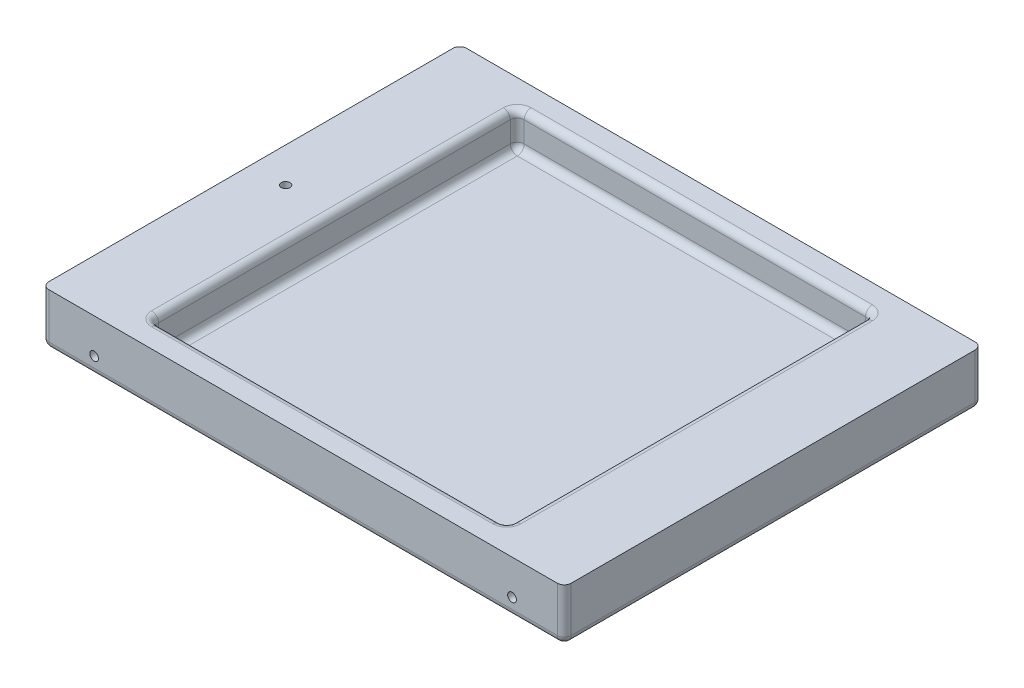
from build123d import *

# Parameters (mm, degrees)
SKETCH2_W               = 1500
SKETCH2_H               = 150
BOSS_EXTRUDE1_DEPTH     = 600
SKETCH3_R               = 12.5
CUT_EXTRUDE2_DEPTH      = 250
MIRROR3_COPY_1_SKETCH_R = 12.5
MIRROR3_COPY_1_DEPTH    = 250
SKETCH4_R               = 12.5
CUT_EXTRUDE3_DEPTH      = 50
SKETCH5_W               = 1020
SKETCH5_H               = 1050
CUT_EXTRUDE4_DEPTH      = 100
FILLET1_R               = 20


with BuildPart() as part:
    # Sketch2 → Boss-Extrude1 (new body, symmetric)
    with BuildSketch(Plane.XY):
        Rectangle(SKETCH2_W, SKETCH2_H)
    extrude(amount=BOSS_EXTRUDE1_DEPTH, both=True)

    # Sketch3 → Cut-Extrude2 (cut)
    with BuildSketch(Plane.XY.offset(600)):
        with Locations((-600, -25)):
            Circle(SKETCH3_R)
    cut_extrude2 = extrude(amount=-CUT_EXTRUDE2_DEPTH, mode=Mode.SUBTRACT)

    # Mirror2: Cut-Extrude2 across plane
    add(cut_extrude2.mirror(Plane(origin=(0, 0, 0), x_dir=(0, 0, 1), z_dir=(1, 0, 0))), mode=Mode.SUBTRACT)

    # Mirror3: Cut-Extrude2 across plane
    add(cut_extrude2.mirror(Plane.XY), mode=Mode.SUBTRACT)

    # Mirror3 copy 1 sketch → Mirror3 copy 1 (cut)
    with BuildSketch(Plane(origin=(0, 0, -600), x_dir=(-1, 0, 0), z_dir=(0, 0, -1))):
        with Locations((-600, -25)):
            Circle(MIRROR3_COPY_1_SKETCH_R)
    extrude(amount=-MIRROR3_COPY_1_DEPTH, mode=Mode.SUBTRACT)

    # Sketch4 → Cut-Extrude3 (cut)
    with BuildSketch(Plane(origin=(0, 75, 0), x_dir=(1, 0, 0), z_dir=(0, 1, 0))):
        with Locations((-650, 0)):
            Circle(SKETCH4_R)
    extrude(amount=-CUT_EXTRUDE3_DEPTH, mode=Mode.SUBTRACT)

    # Sketch5 → Cut-Extrude4 (cut)
    with BuildSketch(Plane(origin=(0, 75, 0), x_dir=(1, 0, 0), z_dir=(0, 1, 0))):
        Rectangle(SKETCH5_W, SKETCH5_H)
    extrude(amount=-CUT_EXTRUDE4_DEPTH, mode=Mode.SUBTRACT)

    # Fillet1
    fillet1_edges = [part.edges().sort_by_distance(p)[0] for p in [
        (-750, 0, 600),
        (0, -75, 600),
        (510, -25, 0),
        (510, 25, -525),
        (0, -25, 525),
        (510, 25, 525),
        (-510, -25, 0),
        (-510, 25, 525),
        (0, -25, -525),
        (-510, 25, -525),
        (510, 75, 0),
        (0, 75, -525),
        (-510, 75, 0),
        (0, 75, 525),
        (750, 0, 600),
        (0, -75, -600),
        (-750, 0, -600),
        (750, 0, -600),
        (750, -75, 0),
        (-750, -75, 0),
    ]]
    fillet(fillet1_edges, radius=FILLET1_R)


solid = part.part
